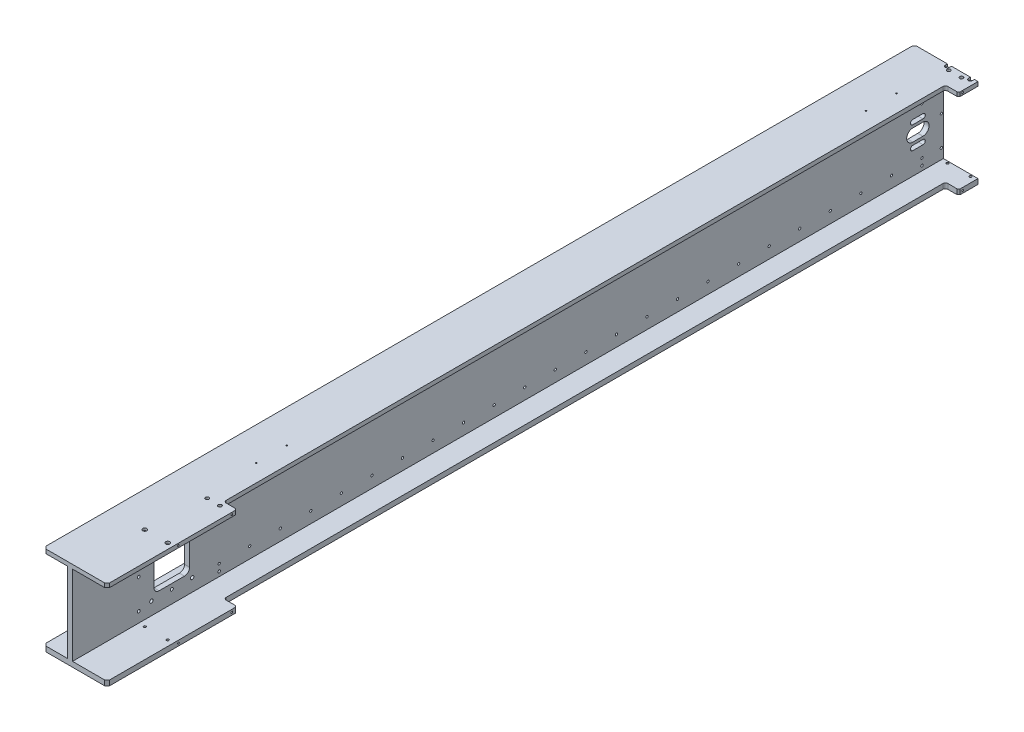
from build123d import *

# Parameters (mm, degrees)
SKETCH1_W                                       = 125
SKETCH1_H                                       = 1710
BOSS_EXTRUDE1_DEPTH                             = 8
BOSS_EXTRUDE2_START                             = -68
SKETCH2_W                                       = 1710
SKETCH2_H                                       = 157
BOSS_EXTRUDE2_DEPTH                             = 10
SKETCH3_W                                       = 125
SKETCH3_H                                       = 1710
BOSS_EXTRUDE3_DEPTH                             = 10
BOSS_EXTRUDE4_START                             = -50
SKETCH4_W                                       = 47
SKETCH4_H                                       = 157
BOSS_EXTRUDE4_DEPTH                             = 8
BOSS_EXTRUDE5_START                             = -500
SKETCH5_W                                       = 47
SKETCH5_H                                       = 157
BOSS_EXTRUDE5_DEPTH                             = 8
BOSS_EXTRUDE6_START                             = -490
SKETCH6_W                                       = 47
SKETCH6_H                                       = 157
BOSS_EXTRUDE6_DEPTH                             = 8
BOSS_EXTRUDE7_START                             = -530
SKETCH7_W                                       = 47
SKETCH7_H                                       = 157
BOSS_EXTRUDE7_DEPTH                             = 8
SKETCH8_W                                       = 26
SKETCH8_H                                       = 1417
CUT_EXTRUDE1_DEPTH                              = 176
CUT_EXTRUDE2_DEPTH                              = 4.5
CUT_EXTRUDE3_DEPTH                              = 4.5
CUT_EXTRUDE4_REACH                              = 59
SKETCH11_W                                      = 70
SKETCH11_H                                      = 70
CUT_EXTRUDE5_REACH                              = 59
SKETCH12_R                                      = 2.5
CUT_EXTRUDE6_REACH                              = 59
CUT_EXTRUDE7_REACH                              = 59
CUT_EXTRUDE8_REACH                              = 59
SKETCH37_R                                      = 3
CUT_EXTRUDE9_DEPTH                              = 1661
CBORE_FOR_M4_SOCKET_HEAD_CAP_SCREW3_D           = 4.5
CBORE_FOR_M4_SOCKET_HEAD_CAP_SCREW3_DEPTH       = 8
CBORE_FOR_M4_SOCKET_HEAD_CAP_SCREW3_CBORE_D     = 8
CBORE_FOR_M4_SOCKET_HEAD_CAP_SCREW3_CBORE_DEPTH = 4.5
CBORE_FOR_M4_SOCKET_HEAD_CAP_SCREW2_D           = 4.5
CBORE_FOR_M4_SOCKET_HEAD_CAP_SCREW2_DEPTH       = 10
CBORE_FOR_M4_SOCKET_HEAD_CAP_SCREW2_CBORE_D     = 8
CBORE_FOR_M4_SOCKET_HEAD_CAP_SCREW2_CBORE_DEPTH = 4.5
M8X1_25_TAPPED_HOLE1_D                          = 6.8
M8X1_25_TAPPED_HOLE1_DEPTH                      = 8
F_5_5_5_5_DIAMETER_HOLE1_D                      = 5.5
F_5_5_5_5_DIAMETER_HOLE1_DEPTH                  = 10
M8X1_25_TAPPED_HOLE3_D                          = 6.8
M8X1_25_TAPPED_HOLE3_DEPTH                      = 10
F_4_5_4_5_DIAMETER_HOLE1_D                      = 4.5
F_4_5_4_5_DIAMETER_HOLE1_DEPTH                  = 10.00105
F_4_5_4_5_DIAMETER_HOLE2_D                      = 4.5
F_4_5_4_5_DIAMETER_HOLE2_DEPTH                  = 10
F_4_5_4_5_DIAMETER_HOLE3_D                      = 4.5
F_4_5_4_5_DIAMETER_HOLE3_DEPTH                  = 3.5
F_4_5_4_5_DIAMETER_HOLE4_D                      = 4.5
F_4_5_4_5_DIAMETER_HOLE4_DEPTH                  = 5.5
LPATTERN1_COUNT                                 = 2
LPATTERN1_PITCH                                 = 106
LPATTERN1_COUNT_DIR2                            = 24
LPATTERN1_PITCH_DIR2                            = 60
M4X0_7_TAPPED_HOLE1_AT_2_COUNT                  = 2
M4X0_7_TAPPED_HOLE1_AT_2_PITCH                  = 105
M4X0_7_TAPPED_HOLE1_AT_3_COUNT                  = 2
M4X0_7_TAPPED_HOLE1_AT_3_PITCH                  = 1540
M3X0_5_TAPPED_HOLE1_D                           = 2.5
M3X0_5_TAPPED_HOLE1_DEPTH                       = 8
LPATTERN3_COUNT                                 = 2
LPATTERN3_PITCH                                 = 1197.5
LPATTERN2_COUNT                                 = 2
LPATTERN2_PITCH                                 = 166
FILLET1_R                                       = 10
FILLET2_R                                       = 5
CHAMFER1_SIZE                                   = 3
CHAMFER2_SIZE                                   = 5


with BuildPart() as part:
    # Sketch1 → Boss-Extrude1 (new body)
    with BuildSketch(Plane(origin=(0, 0, 0), x_dir=(1, 0, 0), z_dir=(0, 1, 0))):
        with Locations((-62.5, 855)):
            Rectangle(SKETCH1_W, SKETCH1_H)
    extrude(amount=-BOSS_EXTRUDE1_DEPTH)

    # Sketch2 → Boss-Extrude2 (add)
    with BuildSketch(Plane(origin=(0, 0, 0), x_dir=(0, 0, -1), z_dir=(1, 0, 0)).offset(BOSS_EXTRUDE2_START)):
        with Locations((855, -86.5)):
            Rectangle(SKETCH2_W, SKETCH2_H)
    extrude(amount=-BOSS_EXTRUDE2_DEPTH)

    # Sketch3 → Boss-Extrude3 (add)
    with BuildSketch(Plane.XZ.offset(165)):
        with Locations((-62.5, -855)):
            Rectangle(SKETCH3_W, SKETCH3_H)
    extrude(amount=BOSS_EXTRUDE3_DEPTH)

    # Sketch4 → Boss-Extrude4 (add)
    with BuildSketch(Plane.XY.offset(BOSS_EXTRUDE4_START)):
        with Locations((-101.5, -86.5)):
            Rectangle(SKETCH4_W, SKETCH4_H)
    extrude(amount=-BOSS_EXTRUDE4_DEPTH)

    # Sketch5 → Boss-Extrude5 (add)
    with BuildSketch(Plane.XY.offset(-50).offset(BOSS_EXTRUDE5_START)):
        with Locations((-101.5, -86.5)):
            Rectangle(SKETCH5_W, SKETCH5_H)
    extrude(amount=-BOSS_EXTRUDE5_DEPTH)

    # Sketch6 → Boss-Extrude6 (add)
    with BuildSketch(Plane.XY.offset(-550).offset(BOSS_EXTRUDE6_START)):
        with Locations((-101.5, -86.5)):
            Rectangle(SKETCH6_W, SKETCH6_H)
    extrude(amount=-BOSS_EXTRUDE6_DEPTH)

    # Sketch7 → Boss-Extrude7 (add)
    with BuildSketch(Plane.XY.offset(-1040).offset(BOSS_EXTRUDE7_START)):
        with Locations((-101.5, -86.5)):
            Rectangle(SKETCH7_W, SKETCH7_H)
    extrude(amount=-BOSS_EXTRUDE7_DEPTH)

    # Sketch8 → Cut-Extrude1 (cut, through all)
    with BuildSketch(Plane(origin=(0, 0, 0), x_dir=(1, 0, 0), z_dir=(0, 1, 0))):
        with Locations((-13, 963.5)):
            Rectangle(SKETCH8_W, SKETCH8_H)
    extrude(amount=-CUT_EXTRUDE1_DEPTH, mode=Mode.SUBTRACT)

    # Sketch9 → Cut-Extrude2 (cut)
    with BuildSketch(Plane(origin=(0, 0, 0), x_dir=(1, 0, 0), z_dir=(0, 1, 0))):
        with BuildLine():
            Line((-60, 1706), (-60, 1710))
            Line((-60, 1710), (-52, 1710))
            Line((-52, 1710), (-52, 1706))
            ThreePointArc((-52, 1706), (-56, 1702), (-60, 1706))
        make_face()
        with BuildLine():
            Line((-15, 1706), (-15, 1710))
            Line((-15, 1710), (-7, 1710))
            Line((-7, 1710), (-7, 1706))
            ThreePointArc((-7, 1706), (-11, 1702), (-15, 1706))
        make_face()
    extrude(amount=-CUT_EXTRUDE2_DEPTH, mode=Mode.SUBTRACT)

    # Sketch10 → Cut-Extrude3 (cut)
    with BuildSketch(Plane.XZ.offset(175)):
        with BuildLine():
            Line((-60, -1710), (-60, -1706))
            ThreePointArc((-60, -1706), (-56, -1702), (-52, -1706))
            Line((-52, -1706), (-52, -1710))
            Line((-52, -1710), (-60, -1710))
        make_face()
        with BuildLine():
            Line((-15, -1710), (-15, -1706))
            ThreePointArc((-15, -1706), (-11, -1702), (-7, -1706))
            Line((-7, -1706), (-7, -1710))
            Line((-7, -1710), (-15, -1710))
        make_face()
    extrude(amount=-CUT_EXTRUDE3_DEPTH, mode=Mode.SUBTRACT)

    # Sketch11 → Cut-Extrude4 (cut, up to next)
    with BuildSketch(Plane(origin=(-68, 0, 0), x_dir=(0, 0, -1), z_dir=(1, 0, 0)), mode=Mode.PRIVATE) as cut_extrude4_sk1:
        with Locations((195, -95)):
            Rectangle(SKETCH11_W, SKETCH11_H)
    cut_extrude4_tool1 = extrude(cut_extrude4_sk1.sketch, amount=-CUT_EXTRUDE4_REACH, mode=Mode.PRIVATE) & part.part
    add(cut_extrude4_tool1.solids().sort_by_distance((-68, -95, -195))[0], mode=Mode.SUBTRACT)

    # Sketch12 → Cut-Extrude5 (cut, up to next)
    with BuildSketch(Plane(origin=(-68, 0, 0), x_dir=(0, 0, -1), z_dir=(1, 0, 0)), mode=Mode.PRIVATE) as cut_extrude5_sk1:
        with Locations((288, -156)):
            Circle(SKETCH12_R)
    cut_extrude5_tool1 = extrude(cut_extrude5_sk1.sketch, amount=-CUT_EXTRUDE5_REACH, mode=Mode.PRIVATE) & part.part
    add(cut_extrude5_tool1.solids().sort_by_distance((-68, -156, -288))[0], mode=Mode.SUBTRACT)
    # Sketch12 → Cut-Extrude5 (cut, up to next)
    with BuildSketch(Plane(origin=(-68, 0, 0), x_dir=(0, 0, -1), z_dir=(1, 0, 0)), mode=Mode.PRIVATE) as cut_extrude5_sk2:
        with Locations((1668, -156)):
            Circle(SKETCH12_R)
    cut_extrude5_tool2 = extrude(cut_extrude5_sk2.sketch, amount=-CUT_EXTRUDE5_REACH, mode=Mode.PRIVATE) & part.part
    add(cut_extrude5_tool2.solids().sort_by_distance((-68, -156, -1668))[0], mode=Mode.SUBTRACT)
    # Sketch12 → Cut-Extrude5 (cut, up to next)
    with BuildSketch(Plane(origin=(-68, 0, 0), x_dir=(0, 0, -1), z_dir=(1, 0, 0)), mode=Mode.PRIVATE) as cut_extrude5_sk3:
        with Locations((1668, -50)):
            Circle(SKETCH12_R)
    cut_extrude5_tool3 = extrude(cut_extrude5_sk3.sketch, amount=-CUT_EXTRUDE5_REACH, mode=Mode.PRIVATE) & part.part
    add(cut_extrude5_tool3.solids().sort_by_distance((-68, -50, -1668))[0], mode=Mode.SUBTRACT)
    # Sketch12 → Cut-Extrude5 (cut, up to next)
    with BuildSketch(Plane(origin=(-68, 0, 0), x_dir=(0, 0, -1), z_dir=(1, 0, 0)), mode=Mode.PRIVATE) as cut_extrude5_sk4:
        with Locations((288, -50)):
            Circle(SKETCH12_R)
    cut_extrude5_tool4 = extrude(cut_extrude5_sk4.sketch, amount=-CUT_EXTRUDE5_REACH, mode=Mode.PRIVATE) & part.part
    add(cut_extrude5_tool4.solids().sort_by_distance((-68, -50, -288))[0], mode=Mode.SUBTRACT)

    # Sketch29 → Cut-Extrude6 (cut, up to next)
    with BuildSketch(Plane(origin=(-68, 0, 0), x_dir=(0, 0, -1), z_dir=(1, 0, 0)), mode=Mode.PRIVATE) as cut_extrude6_sk1:
        with BuildLine():
            Line((1650, -83), (1670, -83))
            ThreePointArc((1670, -83), (1682, -95), (1670, -107))
            Line((1670, -107), (1650, -107))
            ThreePointArc((1650, -107), (1638, -95), (1650, -83))
        make_face()
    cut_extrude6_tool1 = extrude(cut_extrude6_sk1.sketch, amount=-CUT_EXTRUDE6_REACH, mode=Mode.PRIVATE) & part.part
    add(cut_extrude6_tool1.solids().sort_by_distance((-68, -95, -1660))[0], mode=Mode.SUBTRACT)

    # Sketch30 → Cut-Extrude7 (cut, up to next)
    with BuildSketch(Plane(origin=(-68, 0, 0), x_dir=(0, 0, -1), z_dir=(1, 0, 0)), mode=Mode.PRIVATE) as cut_extrude7_sk1:
        with BuildLine():
            Line((1650, -68.5), (1670, -68.5))
            ThreePointArc((1670, -68.5), (1674.5, -73), (1670, -77.5))
            Line((1670, -77.5), (1650, -77.5))
            ThreePointArc((1650, -77.5), (1645.5, -73), (1650, -68.5))
        make_face()
    cut_extrude7_tool1 = extrude(cut_extrude7_sk1.sketch, amount=-CUT_EXTRUDE7_REACH, mode=Mode.PRIVATE) & part.part
    add(cut_extrude7_tool1.solids().sort_by_distance((-68, -73, -1660))[0], mode=Mode.SUBTRACT)
    # Sketch30 → Cut-Extrude7 (cut, up to next)
    with BuildSketch(Plane(origin=(-68, 0, 0), x_dir=(0, 0, -1), z_dir=(1, 0, 0)), mode=Mode.PRIVATE) as cut_extrude7_sk2:
        with BuildLine():
            Line((1650, -121.5), (1670, -121.5))
            ThreePointArc((1670, -121.5), (1674.5, -117), (1670, -112.5))
            Line((1670, -112.5), (1650, -112.5))
            ThreePointArc((1650, -112.5), (1645.5, -117), (1650, -121.5))
        make_face()
    cut_extrude7_tool2 = extrude(cut_extrude7_sk2.sketch, amount=-CUT_EXTRUDE7_REACH, mode=Mode.PRIVATE) & part.part
    add(cut_extrude7_tool2.solids().sort_by_distance((-68, -117, -1660))[0], mode=Mode.SUBTRACT)

    # Sketch37 → Cut-Extrude8 (cut, up to next)
    with BuildSketch(Plane(origin=(-68, 0, 0), x_dir=(0, 0, -1), z_dir=(1, 0, 0)), mode=Mode.PRIVATE) as cut_extrude8_sk1:
        with Locations((195, -50)):
            Circle(SKETCH37_R)
    cut_extrude8_tool1 = extrude(cut_extrude8_sk1.sketch, amount=-CUT_EXTRUDE8_REACH, mode=Mode.PRIVATE) & part.part
    add(cut_extrude8_tool1.solids().sort_by_distance((-68, -50, -195))[0], mode=Mode.SUBTRACT)
    # Sketch37 → Cut-Extrude8 (cut, up to next)
    with BuildSketch(Plane(origin=(-68, 0, 0), x_dir=(0, 0, -1), z_dir=(1, 0, 0)), mode=Mode.PRIVATE) as cut_extrude8_sk2:
        with Locations((195, -140)):
            Circle(SKETCH37_R)
    cut_extrude8_tool2 = extrude(cut_extrude8_sk2.sketch, amount=-CUT_EXTRUDE8_REACH, mode=Mode.PRIVATE) & part.part
    add(cut_extrude8_tool2.solids().sort_by_distance((-68, -140, -195))[0], mode=Mode.SUBTRACT)

    # Sketch40 → Cut-Extrude9 (cut, through all)
    with BuildSketch(Plane.XY.offset(-50)):
        Polygon((-78, -8), (-83, -8), (-78, -13), align=None)
        Polygon((-78, -165), (-78, -160), (-83, -165), align=None)
    extrude(amount=-CUT_EXTRUDE9_DEPTH, mode=Mode.SUBTRACT)

    # CBORE for M4 Socket Head Cap Screw3
    with Locations(Plane(origin=(0, 0, 0), x_dir=(-1, 0, 0), z_dir=(0, 1, 0))):
        with Locations((56, -130), (11, -130)):
            CounterBoreHole(CBORE_FOR_M4_SOCKET_HEAD_CAP_SCREW3_D / 2, CBORE_FOR_M4_SOCKET_HEAD_CAP_SCREW3_CBORE_D / 2, CBORE_FOR_M4_SOCKET_HEAD_CAP_SCREW3_CBORE_DEPTH, depth=CBORE_FOR_M4_SOCKET_HEAD_CAP_SCREW3_DEPTH)

    # CBORE for M4 Socket Head Cap Screw2
    with Locations(Plane.XZ.offset(175)):
        with Locations((-56, -130), (-11, -130)):
            CounterBoreHole(CBORE_FOR_M4_SOCKET_HEAD_CAP_SCREW2_D / 2, CBORE_FOR_M4_SOCKET_HEAD_CAP_SCREW2_CBORE_D / 2, CBORE_FOR_M4_SOCKET_HEAD_CAP_SCREW2_CBORE_DEPTH, depth=CBORE_FOR_M4_SOCKET_HEAD_CAP_SCREW2_DEPTH)

    # M8x1.25 Tapped Hole1
    with Locations(Plane(origin=(0, 0, 0), x_dir=(-1, 0, 0), z_dir=(0, 1, 0))):
        with Locations((48, -244.5), (23, -244.5), (48, -1700.5), (23, -1700.5)):
            Hole(M8X1_25_TAPPED_HOLE1_D / 2, depth=M8X1_25_TAPPED_HOLE1_DEPTH)

    # Ø5.5 (5.5) Diameter Hole1
    with Locations(Plane.ZY.offset(78)):
        with Locations((-130, -28), (-130, -86.5), (-130, -145)):
            Hole(F_5_5_5_5_DIAMETER_HOLE1_D / 2, depth=F_5_5_5_5_DIAMETER_HOLE1_DEPTH)

    # M8x1.25 Tapped Hole3
    with Locations(Plane.ZY.offset(78)):
        with Locations((-155, -50), (-235, -50), (-235, -140), (-155, -140)):
            Hole(M8X1_25_TAPPED_HOLE3_D / 2, depth=M8X1_25_TAPPED_HOLE3_DEPTH)

    # Ø4.5 (4.5) Diameter Hole1
    with Locations(Plane(origin=(-68, 0, 0), x_dir=(0, 0, -1), z_dir=(1, 0, 0))):
        with Locations((288, -37)):
            f_4_5_4_5_diameter_hole1 = Hole(F_4_5_4_5_DIAMETER_HOLE1_D / 2, depth=F_4_5_4_5_DIAMETER_HOLE1_DEPTH)

    # Ø4.5 (4.5) Diameter Hole2
    with Locations(Plane.ZY.offset(78)):
        with Locations((-1706, -28), (-1706, -86.5), (-1706, -145)):
            Hole(F_4_5_4_5_DIAMETER_HOLE2_D / 2, depth=F_4_5_4_5_DIAMETER_HOLE2_DEPTH)

    # Ø4.5 (4.5) Diameter Hole3
    with Locations(Plane(origin=(0, -4.5, 0), x_dir=(-1, 0, 0), z_dir=(0, 1, 0))):
        with Locations((56, -1706), (11, -1706)):
            Hole(F_4_5_4_5_DIAMETER_HOLE3_D / 2, depth=F_4_5_4_5_DIAMETER_HOLE3_DEPTH)

    # Ø4.5 (4.5) Diameter Hole4
    with Locations(Plane.XZ.offset(170.5)):
        with Locations((-11, -1706), (-56, -1706)):
            Hole(F_4_5_4_5_DIAMETER_HOLE4_D / 2, depth=F_4_5_4_5_DIAMETER_HOLE4_DEPTH)

    # LPattern1: 4.5 _4.5_ Diameter Hole1 2 × 24
    with Locations(*[(0, -i * LPATTERN1_PITCH, -j * LPATTERN1_PITCH_DIR2) for i in range(LPATTERN1_COUNT) for j in range(LPATTERN1_COUNT_DIR2) if (i, j) != (0, 0)]):
        add(f_4_5_4_5_diameter_hole1, mode=Mode.SUBTRACT)

    # Sketch31 → M4x0.7 Tapped Hole1 (revolve, cut)
    with BuildSketch(Plane(origin=(0, -4, -140), x_dir=(0, 0, -1), z_dir=(0, 1, 0))):
        Polygon((0, 0), (0, 11.091420021), (1.65, 10.1), (1.65, 0), align=None)
    m4x0_7_tapped_hole1 = revolve(axis=Axis((6.35, -4, -140), (-1, 0, 0)), mode=Mode.SUBTRACT)

    # M4x0.7 Tapped Hole1 at 2: M4x0.7 Tapped Hole1 ×2
    with Locations(*[(0, 0, -i * M4X0_7_TAPPED_HOLE1_AT_2_PITCH) for i in range(1, M4X0_7_TAPPED_HOLE1_AT_2_COUNT)]):
        add(m4x0_7_tapped_hole1, mode=Mode.SUBTRACT)

    # M4x0.7 Tapped Hole1 at 3: M4x0.7 Tapped Hole1 ×2
    with Locations(*[(0, 0, -i * M4X0_7_TAPPED_HOLE1_AT_3_PITCH) for i in range(1, M4X0_7_TAPPED_HOLE1_AT_3_COUNT)]):
        add(m4x0_7_tapped_hole1, mode=Mode.SUBTRACT)

    # M3x0.5 Tapped Hole1
    with Locations(Plane(origin=(0, 0, 0), x_dir=(-1, 0, 0), z_dir=(0, 1, 0))):
        with Locations((60, -352.5), (60, -412.5)):
            m3x0_5_tapped_hole1 = Hole(M3X0_5_TAPPED_HOLE1_D / 2, depth=M3X0_5_TAPPED_HOLE1_DEPTH)

    # LPattern3: M3x0.5 Tapped Hole1 ×2
    with Locations(*[(0, 0, -i * LPATTERN3_PITCH) for i in range(1, LPATTERN3_COUNT)]):
        add(m3x0_5_tapped_hole1, mode=Mode.SUBTRACT)

    # LPattern2: M4x0.7 Tapped Hole1 ×2
    with Locations(*[(0, -i * LPATTERN2_PITCH, 0) for i in range(1, LPATTERN2_COUNT)]):
        add(m4x0_7_tapped_hole1, mode=Mode.SUBTRACT)

    # LPattern2 copy 1 sketch → LPattern2 copy 1 (revolve, cut)
    with BuildSketch(Plane(origin=(0, -170, -245), x_dir=(0, 0, -1), z_dir=(0, 1, 0))):
        Polygon((0, 0), (0, 11.091420021), (1.65, 10.1), (1.65, 0), align=None)
    revolve(axis=Axis((6.35, -170, -245), (-1, 0, 0)), mode=Mode.SUBTRACT)

    # LPattern2 copy 2 sketch → LPattern2 copy 2 (revolve, cut)
    with BuildSketch(Plane(origin=(0, -170, -1680), x_dir=(0, 0, -1), z_dir=(0, 1, 0))):
        Polygon((0, 0), (0, 11.091420021), (1.65, 10.1), (1.65, 0), align=None)
    revolve(axis=Axis((6.35, -170, -1680), (-1, 0, 0)), mode=Mode.SUBTRACT)

    # Fillet1
    fillet1_edges = [part.edges().sort_by_distance(p)[0] for p in [
        (-73, -130, -160),
        (-73, -60, -160),
        (-73, -60, -230),
        (-73, -130, -230),
    ]]
    fillet(fillet1_edges, radius=FILLET1_R)

    # Fillet2
    fillet2_edges = [part.edges().sort_by_distance(p)[0] for p in [
        (-26, -170, -255),
        (-26, -170, -1672),
        (-26, -4, -255),
        (-26, -4, -1672),
    ]]
    fillet(fillet2_edges, radius=FILLET2_R)

    # Chamfer1
    chamfer1_edges = [part.edges().sort_by_distance(p)[0] for p in [
        (0, -170, -1672),
        (0, -170, -255),
        (0, -4, -1672),
        (0, -4, -255),
    ]]
    chamfer(chamfer1_edges, length=CHAMFER1_SIZE)

    # Chamfer2
    chamfer2_edges = [part.edges().sort_by_distance(p)[0] for p in [
        (-125, -170, -1710),
        (-125, -4, -1710),
        (-125, -170, 0),
        (-125, -4, 0),
        (0, -170, 0),
        (0, -4, 0),
    ]]
    chamfer(chamfer2_edges, length=CHAMFER2_SIZE)


solid = part.part
